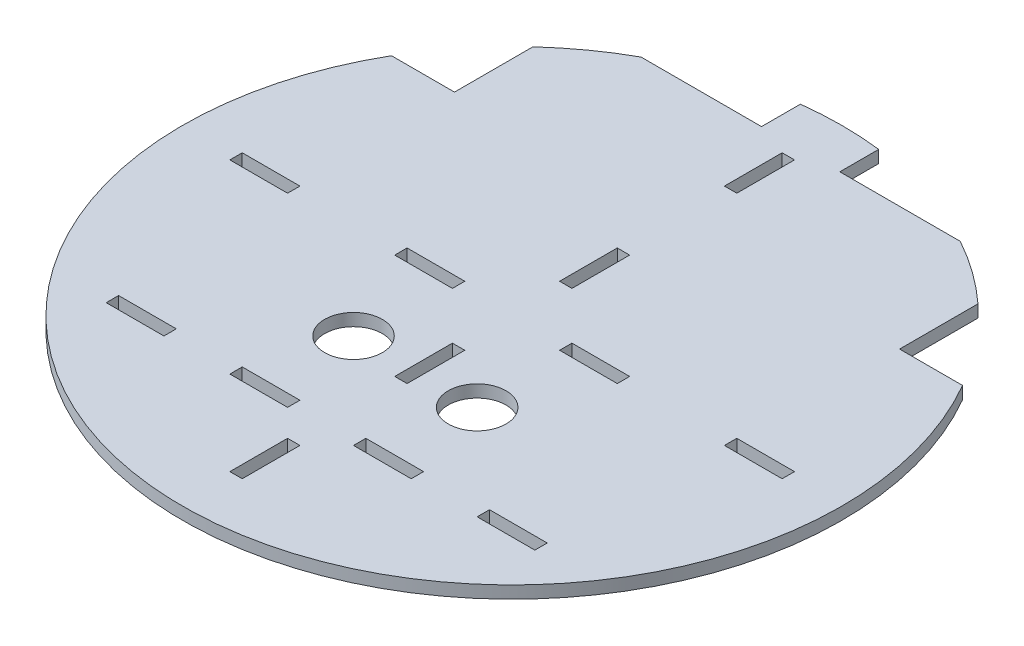
from build123d import *

# Parameters (mm, degrees)
SKETCH1_R               = 80
BOSS_EXTRUDE1_DEPTH     = 3
SKETCH2_W               = 3
SKETCH2_H               = 14
SKETCH2_W_2             = 14
SKETCH2_H_2             = 3
CUT_EXTRUDE1_DEPTH      = 3
CUT_EXTRUDE3_DEPTH      = 1
CUT_EXTRUDE3_DEPTH_BACK = 3
CUT_EXTRUDE4_DEPTH      = 1
CUT_EXTRUDE4_DEPTH_BACK = 3
CUT_EXTRUDE5_DEPTH      = 1
CUT_EXTRUDE5_DEPTH_BACK = 3
CUT_EXTRUDE6_DEPTH      = 1
CUT_EXTRUDE6_DEPTH_BACK = 3
SKETCH7_R               = 7
CUT_EXTRUDE7_DEPTH      = 3


with BuildPart() as part:
    # Sketch1 → Boss-Extrude1 (new body)
    with BuildSketch(Plane(origin=(0, 0, 0), x_dir=(1, 0, 0), z_dir=(0, 1, 0))):
        Circle(SKETCH1_R)
    extrude(amount=BOSS_EXTRUDE1_DEPTH)

    # Sketch2 → Cut-Extrude1 (cut)
    with BuildSketch(Plane(origin=(0, 3, 0), x_dir=(1, 0, 0), z_dir=(0, 1, 0))):
        with Locations((0, 20)):
            Rectangle(SKETCH2_W, SKETCH2_H)
        with Locations((0, 60)):
            Rectangle(SKETCH2_W, SKETCH2_H)
        with Locations((-20, 0)):
            Rectangle(SKETCH2_W_2, SKETCH2_H_2)
        with Locations((-60, 0)):
            Rectangle(SKETCH2_W_2, SKETCH2_H_2)
        with Locations((20, 0)):
            Rectangle(SKETCH2_W_2, SKETCH2_H_2)
        with Locations((60, 0)):
            Rectangle(SKETCH2_W_2, SKETCH2_H_2)
        with Locations((0, -20)):
            Rectangle(SKETCH2_W, SKETCH2_H)
        with Locations((0, -60)):
            Rectangle(SKETCH2_W, SKETCH2_H)
        with Locations((-15, -45)):
            Rectangle(SKETCH2_W_2, SKETCH2_H_2)
        with Locations((15, -45)):
            Rectangle(SKETCH2_W_2, SKETCH2_H_2)
        with Locations((-45, -45)):
            Rectangle(SKETCH2_W_2, SKETCH2_H_2)
        with Locations((45, -45)):
            Rectangle(SKETCH2_W_2, SKETCH2_H_2)
    extrude(amount=-CUT_EXTRUDE1_DEPTH, mode=Mode.SUBTRACT)

    # Sketch3 → Cut-Extrude3 (cut, two sides)
    with BuildSketch(Plane(origin=(0, 3, 0), x_dir=(1, 0, 0), z_dir=(0, 1, 0))) as cut_extrude3_sk:
        Polygon((-465.463683449, 40), (-69.282032303, 40), (-54, 40), (-54, 59.025418253), (-54, 455.2070694), (-616.816816127, 1012.949693112), (-1028.280499576, 597.742623712), align=None)
    extrude(amount=CUT_EXTRUDE3_DEPTH, mode=Mode.SUBTRACT)
    extrude(cut_extrude3_sk.sketch, amount=-CUT_EXTRUDE3_DEPTH_BACK, mode=Mode.SUBTRACT)

    # Sketch4 → Cut-Extrude4 (cut, two sides)
    with BuildSketch(Plane(origin=(0, 3, 0), x_dir=(1, 0, 0), z_dir=(0, 1, 0))) as cut_extrude4_sk:
        Polygon((465.463683449, 40), (69.282032303, 40), (54, 40), (54, 59.025418253), (54, 455.2070694), (616.816816127, 1012.949693112), (1028.280499576, 597.742623712), align=None)
    extrude(amount=CUT_EXTRUDE4_DEPTH, mode=Mode.SUBTRACT)
    extrude(cut_extrude4_sk.sketch, amount=-CUT_EXTRUDE4_DEPTH_BACK, mode=Mode.SUBTRACT)

    # Sketch5 → Cut-Extrude5 (cut, two sides)
    with BuildSketch(Plane(origin=(0, 3, 0), x_dir=(1, 0, 0), z_dir=(0, 1, 0))) as cut_extrude5_sk:
        Polygon((-431.335496535, 70), (-38.729833462, 70), (-9.5, 70), (-9.5, 79.433934814), (-9.5, 472.039597887), (-551.23098741, 1040.444703413), (-973.066483945, 638.405105526), align=None)
    extrude(amount=CUT_EXTRUDE5_DEPTH, mode=Mode.SUBTRACT)
    extrude(cut_extrude5_sk.sketch, amount=-CUT_EXTRUDE5_DEPTH_BACK, mode=Mode.SUBTRACT)

    # Sketch6 → Cut-Extrude6 (cut, two sides)
    with BuildSketch(Plane(origin=(0, 3, 0), x_dir=(1, 0, 0), z_dir=(0, 1, 0))) as cut_extrude6_sk:
        Polygon((431.335496535, 70), (38.729833462, 70), (9.5, 70), (9.5, 79.433934814), (9.5, 472.039597887), (551.23098741, 1040.444703413), (973.066483945, 638.405105526), align=None)
    extrude(amount=CUT_EXTRUDE6_DEPTH, mode=Mode.SUBTRACT)
    extrude(cut_extrude6_sk.sketch, amount=-CUT_EXTRUDE6_DEPTH_BACK, mode=Mode.SUBTRACT)

    # Sketch7 → Cut-Extrude7 (cut)
    with BuildSketch(Plane(origin=(0, 3, 0), x_dir=(1, 0, 0), z_dir=(0, 1, 0))):
        with Locations((-15, -23.5)):
            Circle(SKETCH7_R)
        with Locations((15, -23.5)):
            Circle(SKETCH7_R)
    extrude(amount=-CUT_EXTRUDE7_DEPTH, mode=Mode.SUBTRACT)


solid = part.part
